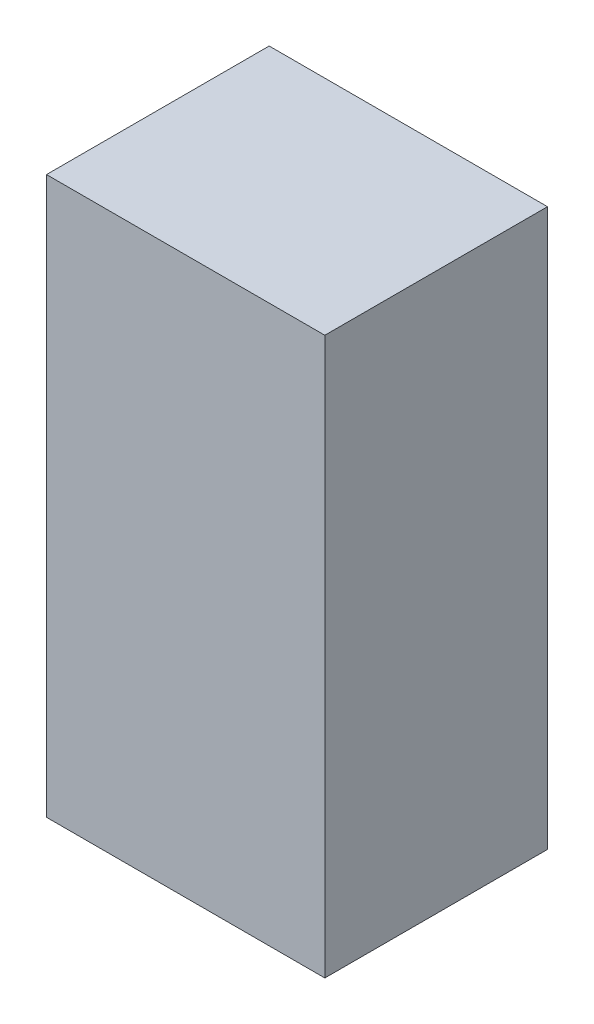
from build123d import *

# Parameters (mm, degrees)
SKETCH1_W           = 0.75
SKETCH1_H           = 0.6
BOSS_EXTRUDE1_DEPTH = 1.5
SCALE1_SCALE        = 10


with BuildPart() as part:
    # Sketch1 → Boss-Extrude1 (new body)
    with BuildSketch(Plane(origin=(0, 0, 0), x_dir=(1, 0, 0), z_dir=(0, 1, 0))):
        with Locations((0.375, 0.3)):
            Rectangle(SKETCH1_W, SKETCH1_H)
    extrude(amount=BOSS_EXTRUDE1_DEPTH)


with BuildPart() as part_1:
    # Scale1: scaled about (0.375, 0.75, -0.3)
    add(part.part.scale(SCALE1_SCALE).moved(Location((-3.375, -6.75, 2.7))))


solid = part_1.part
